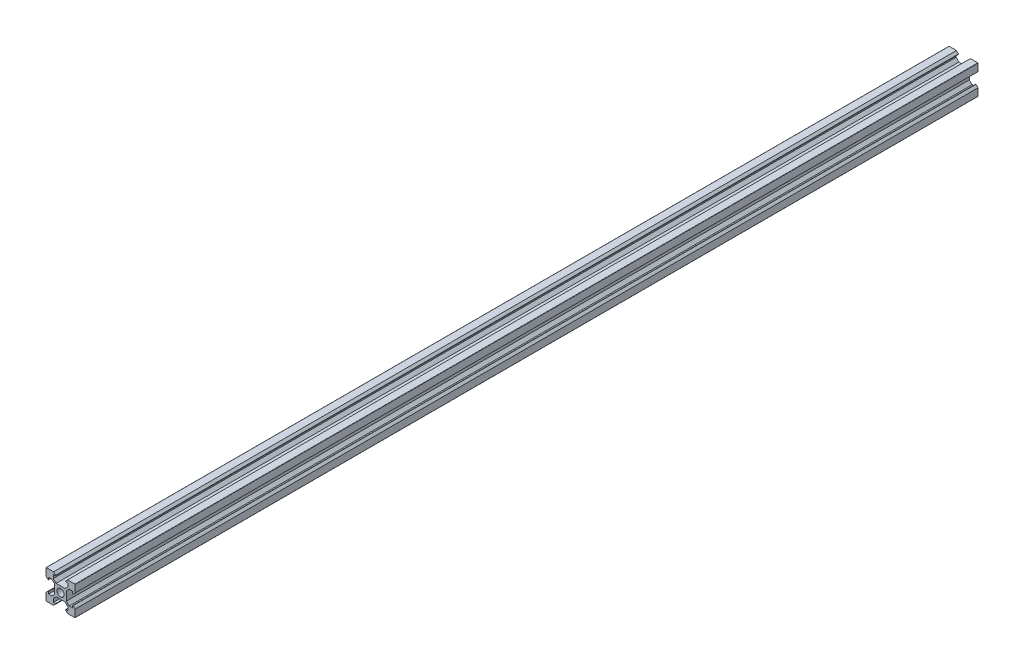
from build123d import *

# Parameters (mm, degrees)
SKETCH1_R           = 2.5
BOSS_EXTRUDE5_DEPTH = 620


with BuildPart() as part:
    # Sketch1 → Boss-Extrude5 (new body)
    with BuildSketch(Plane.XY):
        with BuildLine():
            Line((-10, 9.810918806), (-10, 4.8))
            Line((-10, 4.8), (-8.622781789, 3.422781789))
            ThreePointArc((-8.622781789, 3.422781789), (-8.416722954, 3.381794139), (-8.3, 3.556482384))
            Line((-8.3, 3.556482384), (-8.3, 5))
            Line((-8.3, 5), (-5.919238816, 5))
            Line((-5.919238816, 5), (-4, 3.080761184))
            Line((-4, 3.080761184), (-4, -3.080761184))
            Line((-4, -3.080761184), (-5.919238816, -5))
            Line((-5.919238816, -5), (-8.3, -5))
            Line((-8.3, -5), (-8.3, -3.556482384))
            ThreePointArc((-8.3, -3.556482384), (-8.416722954, -3.381794139), (-8.622781789, -3.422781789))
            Line((-8.622781789, -3.422781789), (-10, -4.8))
            Line((-10, -4.8), (-10, -9.810918806))
            ThreePointArc((-10, -9.810918806), (-9.9446194, -9.9446194), (-9.810918806, -10))
            Line((-9.810918806, -10), (-4.8, -10))
            Line((-4.8, -10), (-3.422781789, -8.622781789))
            ThreePointArc((-3.422781789, -8.622781789), (-3.381794139, -8.416722954), (-3.556482384, -8.3))
            Line((-3.556482384, -8.3), (-5, -8.3))
            Line((-5, -8.3), (-5, -5.919238816))
            Line((-5, -5.919238816), (-3.080761184, -4))
            Line((-3.080761184, -4), (0, -4))
            Line((0, -4), (3.080761184, -4))
            Line((3.080761184, -4), (5, -5.919238816))
            Line((5, -5.919238816), (5, -8.3))
            Line((5, -8.3), (3.556482384, -8.3))
            ThreePointArc((3.556482384, -8.3), (3.381794139, -8.416722954), (3.422781789, -8.622781789))
            Line((3.422781789, -8.622781789), (4.8, -10))
            Line((4.8, -10), (9.810918806, -10))
            ThreePointArc((9.810918806, -10), (9.9446194, -9.9446194), (10, -9.810918806))
            Line((10, -9.810918806), (10, -4.8))
            Line((10, -4.8), (8.622781789, -3.422781789))
            ThreePointArc((8.622781789, -3.422781789), (8.416722954, -3.381794139), (8.3, -3.556482384))
            Line((8.3, -3.556482384), (8.3, -5))
            Line((8.3, -5), (5.919238816, -5))
            Line((5.919238816, -5), (4, -3.080761184))
            Line((4, -3.080761184), (4, 3.080761184))
            Line((4, 3.080761184), (5.919238816, 5))
            Line((5.919238816, 5), (8.3, 5))
            Line((8.3, 5), (8.3, 3.556482384))
            ThreePointArc((8.3, 3.556482384), (8.416722954, 3.381794139), (8.622781789, 3.422781789))
            Line((8.622781789, 3.422781789), (10, 4.8))
            Line((10, 4.8), (10, 9.810918806))
            ThreePointArc((10, 9.810918806), (9.9446194, 9.9446194), (9.810918806, 10))
            Line((9.810918806, 10), (4.8, 10))
            Line((4.8, 10), (3.422781789, 8.622781789))
            ThreePointArc((3.422781789, 8.622781789), (3.381794139, 8.416722954), (3.556482384, 8.3))
            Line((3.556482384, 8.3), (5, 8.3))
            Line((5, 8.3), (5, 5.919238816))
            Line((5, 5.919238816), (3.080761184, 4))
            Line((3.080761184, 4), (-3.080761184, 4))
            Line((-3.080761184, 4), (-5, 5.919238816))
            Line((-5, 5.919238816), (-5, 8.3))
            Line((-5, 8.3), (-3.556482384, 8.3))
            ThreePointArc((-3.556482384, 8.3), (-3.381794139, 8.416722954), (-3.422781789, 8.622781789))
            Line((-3.422781789, 8.622781789), (-4.8, 10))
            Line((-4.8, 10), (-9.810918806, 10))
            ThreePointArc((-9.810918806, 10), (-9.9446194, 9.9446194), (-10, 9.810918806))
        make_face()
        Circle(SKETCH1_R, mode=Mode.SUBTRACT)
    extrude(amount=BOSS_EXTRUDE5_DEPTH)


solid = part.part
